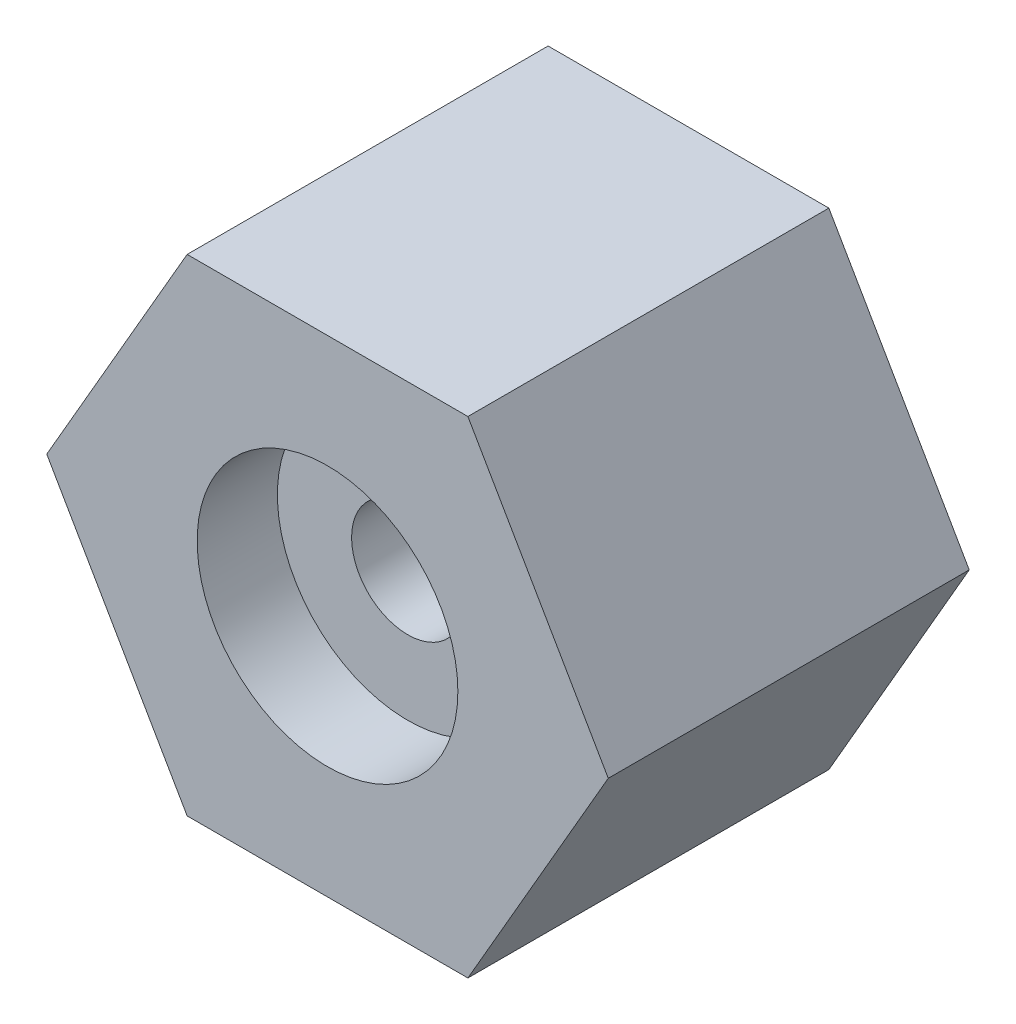
from build123d import *

# Parameters (mm, degrees)
BOSS_EXTRUDE1_DEPTH = 22.5
SKETCH2_R           = 16.25
CUT_EXTRUDE1_DEPTH  = 10
SKETCH3_R           = 7
CUT_EXTRUDE2_DEPTH  = 25


with BuildPart() as part:
    # Sketch1 → Boss-Extrude1 (new body, symmetric)
    with BuildSketch(Plane.XY):
        Polygon((-17.5, 30.310889132), (17.5, 30.310889132), (35, 0), (17.5, -30.310889132), (-17.5, -30.310889132), (-35, 0), align=None)
    extrude(amount=BOSS_EXTRUDE1_DEPTH, both=True)

    # Sketch2 → Cut-Extrude1 (cut)
    with BuildSketch(Plane.XY.offset(22.5)):
        Circle(SKETCH2_R)
    cut_extrude1 = extrude(amount=-CUT_EXTRUDE1_DEPTH, mode=Mode.SUBTRACT)

    # Mirror1: Cut-Extrude1 across plane
    add(cut_extrude1.mirror(Plane.XY), mode=Mode.SUBTRACT)

    # Sketch3 → Cut-Extrude2 (cut)
    with BuildSketch(Plane(origin=(0, 0, -12.5), x_dir=(-1, 0, 0), z_dir=(0, 0, -1))):
        Circle(SKETCH3_R)
    extrude(amount=-CUT_EXTRUDE2_DEPTH, mode=Mode.SUBTRACT)


solid = part.part
